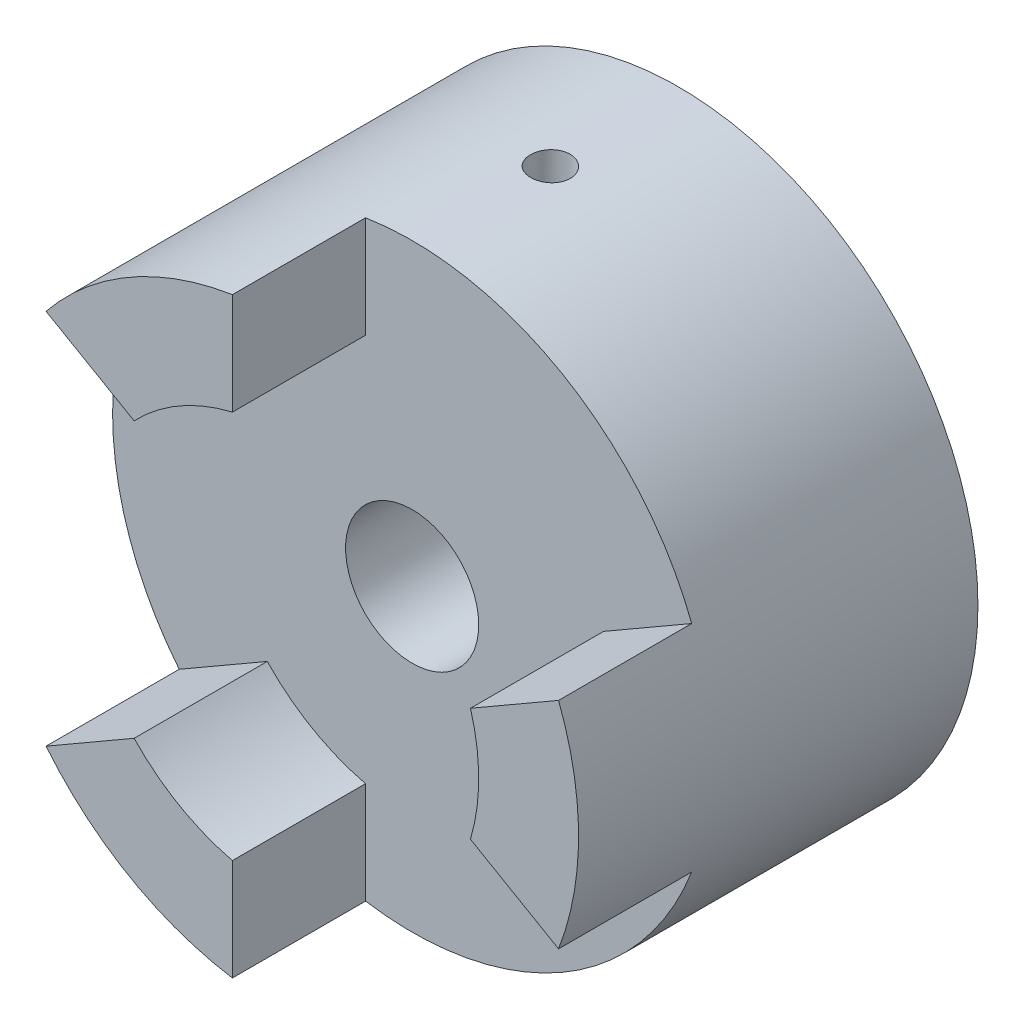
from build123d import *

# Parameters (mm, degrees)
SKETCH1_R                 = 22.5
BOSS_EXTRUDE1_DEPTH       = 20
CUT_EXTRUDE1_REACH        = 22
SKETCH3_R                 = 5
F_3_0MM_DOWEL_HOLE1_D     = 3
F_3_0MM_DOWEL_HOLE1_DEPTH = 22
F_3_0MM_DOWEL_HOLE1_TIP   = 0.901291
BOSS_EXTRUDE3_DEPTH       = 10


with BuildPart() as part:
    # Sketch1 → Boss-Extrude1 (new body)
    with BuildSketch(Plane.XY):
        Circle(SKETCH1_R)
    extrude(amount=BOSS_EXTRUDE1_DEPTH)

    # Sketch3 → Cut-Extrude1 (cut, up to next)
    with BuildSketch(Plane.XY.offset(20), mode=Mode.PRIVATE) as cut_extrude1_sk1:
        Circle(SKETCH3_R)
    cut_extrude1_tool1 = extrude(cut_extrude1_sk1.sketch, amount=-CUT_EXTRUDE1_REACH, mode=Mode.PRIVATE) & part.part
    add(cut_extrude1_tool1.solids().sort_by_distance((0, 0, 20))[0], mode=Mode.SUBTRACT)

    # Ø3.0mm Dowel Hole1
    with Locations(Plane(origin=(0.332625, 22.497541, 9.950984), x_dir=(0.999891, -0.014783, 0), z_dir=(0.014783, 0.999891, 0))):
        with Locations((0, 0)):
            Hole(F_3_0MM_DOWEL_HOLE1_D / 2, depth=F_3_0MM_DOWEL_HOLE1_DEPTH)
            with Locations((0, 0, -(F_3_0MM_DOWEL_HOLE1_DEPTH + F_3_0MM_DOWEL_HOLE1_TIP / 2))):  # 118° drill point
                Cone(0, F_3_0MM_DOWEL_HOLE1_D / 2, F_3_0MM_DOWEL_HOLE1_TIP, mode=Mode.SUBTRACT)

    # Sketch6 → Boss-Extrude3 (add)
    with BuildSketch(Plane.XY.offset(20)):
        with BuildLine():
            Line((-17.498377, 14.144144), (-10.881805, 10.324065))
            ThreePointArc((-10.881805, 10.324065), (-7.5, 12.990381), (-3.5, 14.585952))
            Line((-3.5, 14.585952), (-3.5, 22.226111))
            ThreePointArc((-3.5, 22.226111), (-11.25, 19.485572), (-17.498377, 14.144144))
        make_face()
        with BuildLine():
            Line((14.381805, 4.261887), (20.998377, 8.081966))
            ThreePointArc((20.998377, 8.081966), (22.5, 0), (20.998377, -8.081966))
            Line((20.998377, -8.081966), (14.381805, -4.261887))
            ThreePointArc((14.381805, -4.261887), (15, 0), (14.381805, 4.261887))
        make_face()
        with BuildLine():
            Line((-3.5, -14.585952), (-3.5, -22.226111))
            ThreePointArc((-3.5, -22.226111), (-11.25, -19.485572), (-17.498377, -14.144144))
            Line((-17.498377, -14.144144), (-10.881805, -10.324065))
            ThreePointArc((-10.881805, -10.324065), (-7.5, -12.990381), (-3.5, -14.585952))
        make_face()
    extrude(amount=BOSS_EXTRUDE3_DEPTH)


solid = part.part
